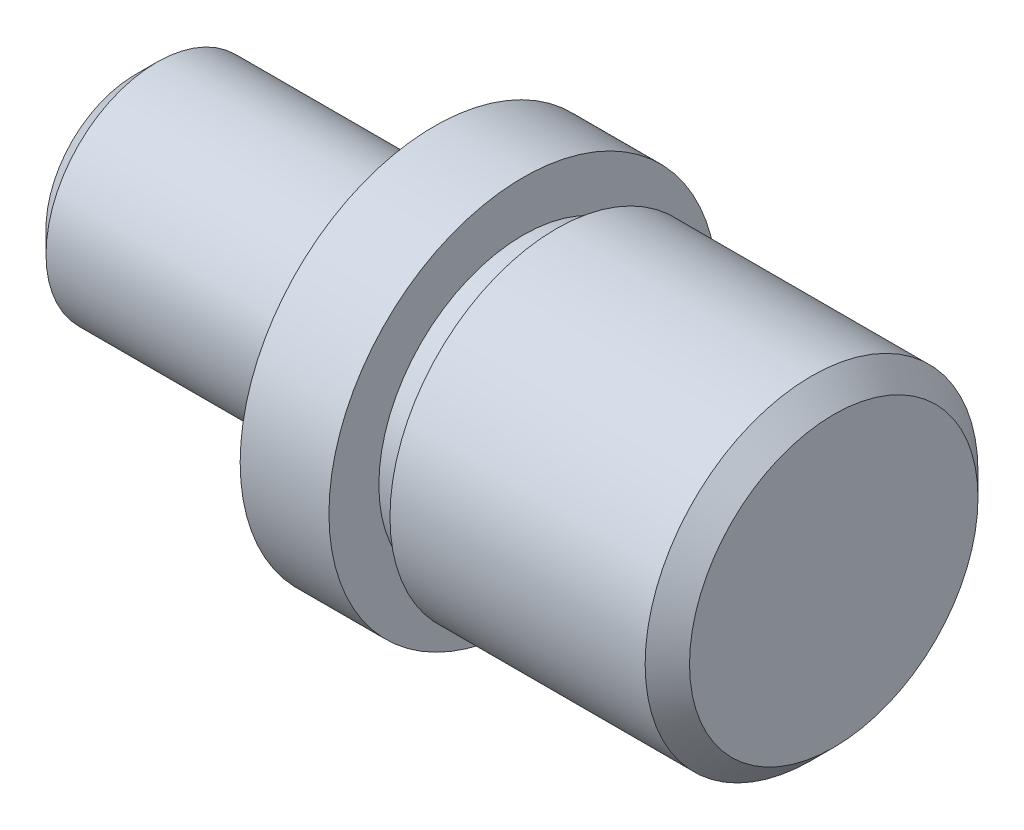
from build123d import *

# Parameters (mm, degrees)
CHAMFER_1_SIZE = 2


with BuildPart() as part:
    # 草图1 → 旋转1 (revolve)
    with BuildSketch(Plane.XY):
        Polygon((0, 0), (0, 10), (25, 10), (25, 8), (27, 8), (27, 17.5), (35, 17.5), (35, 13), (38, 13), (38, 15), (63, 15), (63, 0), align=None)
    revolve(axis=Axis((-82.844288888, 0, 0), (1, 0, 0)))

    # 倒角1
    chamfer_1_edges = [part.edges().sort_by_distance(p)[0] for p in [
        (0, -10, 0),
        (63, -15, 0),
    ]]
    chamfer(chamfer_1_edges, length=CHAMFER_1_SIZE)


solid = part.part
